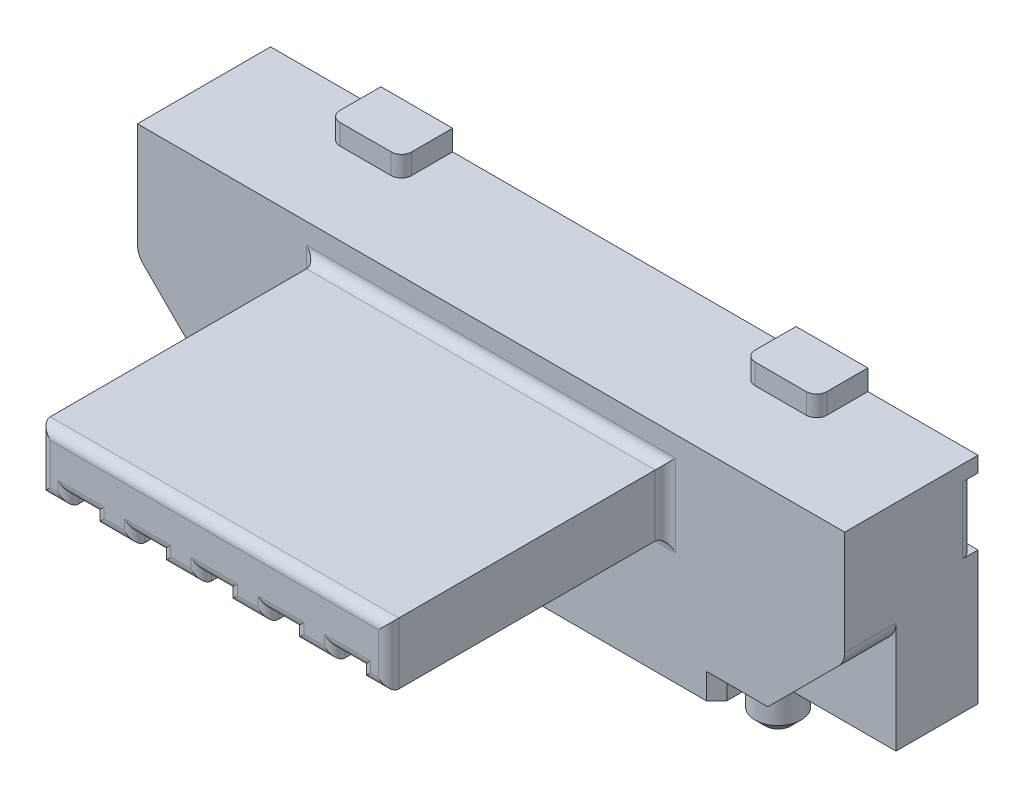
from build123d import *

# Parameters (mm, degrees)
SKETCH1_W           = 6.9
SKETCH1_H           = 1.3
BOSS_EXTRUDE1_DEPTH = 2.1
SKETCH2_W           = 3.4
SKETCH2_H           = 0.6
BOSS_EXTRUDE2_DEPTH = 2.7
SKETCH3_W           = 0.25
SKETCH3_H           = 0.1
CUT_EXTRUDE1_DEPTH  = 3
FILLET1_R           = 0.1
CUT_EXTRUDE2_DEPTH  = 0.5
FILLET3_R           = 0.2
CHAMFER1_SIZE       = 0.1
CUT_EXTRUDE3_DEPTH  = 0.05
FILLET4_R           = 0.1
SKETCH6_R           = 0.225
BOSS_EXTRUDE3_DEPTH = 0.6
CHAMFER2_SIZE       = 0.1
SKETCH7_W           = 3.4
SKETCH7_H           = 0.7
CUT_EXTRUDE4_DEPTH  = 0.3
BOSS_EXTRUDE4_DEPTH = 0.2


with BuildPart() as part:
    # Sketch1 → Boss-Extrude1 (new body)
    with BuildSketch(Plane(origin=(0, 0, 0), x_dir=(1, 0, 0), z_dir=(0, 1, 0))):
        with Locations((0, 4.15)):
            Rectangle(SKETCH1_W, SKETCH1_H)
    extrude(amount=BOSS_EXTRUDE1_DEPTH)

    # Sketch2 → Boss-Extrude2 (add)
    with BuildSketch(Plane.XY.offset(-3.5)):
        with Locations((0, 1.5)):
            Rectangle(SKETCH2_W, SKETCH2_H)
    extrude(amount=BOSS_EXTRUDE2_DEPTH)

    # Sketch3 → Cut-Extrude1 (cut)
    with BuildSketch(Plane.XY.offset(-0.8)):
        with Locations((-1.3, 1.25)):
            Rectangle(SKETCH3_W, SKETCH3_H)
        with Locations((-0.65, 1.25)):
            Rectangle(SKETCH3_W, SKETCH3_H)
        with Locations((0, 1.25)):
            Rectangle(SKETCH3_W, SKETCH3_H)
        with Locations((0.65, 1.25)):
            Rectangle(SKETCH3_W, SKETCH3_H)
        with Locations((1.3, 1.25)):
            Rectangle(SKETCH3_W, SKETCH3_H)
    extrude(amount=-CUT_EXTRUDE1_DEPTH, mode=Mode.SUBTRACT)

    # Fillet1
    fillet1_edges = [part.edges().sort_by_distance(p)[0] for p in [
        (0, 1.8, -0.8),
        (1.7, 1.5, -0.8),
        (1.5625, 1.2, -0.8),
        (-1.5625, 1.2, -0.8),
        (-1.7, 1.5, -0.8),
        (-1.7, 1.5, -3.5),
        (0, 1.8, -3.5),
        (1.7, 1.5, -3.5),
        (1.5625, 1.2, -3.5),
        (-1.5625, 1.2, -3.5),
        (0.975, 1.2, -0.8),
        (0.775, 1.25, -0.8),
        (0.65, 1.3, -0.8),
        (0.525, 1.25, -0.8),
        (0.325, 1.2, -0.8),
        (0.125, 1.25, -0.8),
        (0, 1.3, -0.8),
        (-0.125, 1.25, -0.8),
        (-0.325, 1.2, -0.8),
        (-0.525, 1.25, -0.8),
        (-0.65, 1.3, -0.8),
        (-0.775, 1.25, -0.8),
        (-0.975, 1.2, -0.8),
        (-1.175, 1.25, -0.8),
        (-1.3, 1.3, -0.8),
        (-1.425, 1.25, -0.8),
        (1.425, 1.25, -0.8),
        (1.3, 1.3, -0.8),
        (1.175, 1.25, -0.8),
        (0.975, 1.2, -3.5),
        (0.325, 1.2, -3.5),
        (-0.325, 1.2, -3.5),
        (-0.975, 1.2, -3.5),
    ]]
    fillet(fillet1_edges, radius=FILLET1_R)

    # Sketch4 → Cut-Extrude2 (cut)
    with BuildSketch(Plane.XY.offset(-3.5)):
        Polygon((-2.7, 0.25), (-3.45, 1), (-3.45, 0), (-2.2, 0), (-2.2, 0.25), align=None)
        Polygon((3.45, 1), (2.7, 0.25), (2.2, 0.25), (2.2, 0), (3.45, 0), align=None)
    extrude(amount=-CUT_EXTRUDE2_DEPTH, mode=Mode.SUBTRACT)

    # Fillet3
    fillet3_edges = [part.edges().sort_by_distance(p)[0] for p in [
        (-3.45, 1, -3.75),
        (3.45, 1, -3.75),
    ]]
    fillet(fillet3_edges, radius=FILLET3_R)

    # Chamfer1
    chamfer1_edges = [part.edges().sort_by_distance(p)[0] for p in [
        (-2.2, 0.125, -3.5),
        (2.2, 0.125, -3.5),
    ]]
    chamfer(chamfer1_edges, length=CHAMFER1_SIZE)

    # Sketch5 → Cut-Extrude3 (cut)
    with BuildSketch(Plane(origin=(0, 0, -4.8), x_dir=(-1, 0, 0), z_dir=(0, 0, -1))):
        with BuildLine():
            Line((-3.45, 1.95), (-2.25, 1.95))
            ThreePointArc((-2.25, 1.95), (-2.073223305, 1.876776695), (-2, 1.7))
            Line((-2, 1.7), (-2, 1.55))
            ThreePointArc((-2, 1.55), (-2.073223305, 1.373223305), (-2.25, 1.3))
            Line((-2.25, 1.3), (-3.45, 1.3))
            Line((-3.45, 1.3), (-3.45, 1.95))
        make_face()
        with BuildLine():
            Line((3.45, 1.95), (2.25, 1.95))
            ThreePointArc((2.25, 1.95), (2.073223305, 1.876776695), (2, 1.7))
            Line((2, 1.7), (2, 1.55))
            ThreePointArc((2, 1.55), (2.073223305, 1.373223305), (2.25, 1.3))
            Line((2.25, 1.3), (3.45, 1.3))
            Line((3.45, 1.3), (3.45, 1.95))
        make_face()
    extrude(amount=-CUT_EXTRUDE3_DEPTH, mode=Mode.SUBTRACT)

    # Fillet4
    fillet4_edges = [part.edges().sort_by_distance(p)[0] for p in [
        (3.45, 1.625, -4.75),
        (-3.45, 1.625, -4.75),
    ]]
    fillet(fillet4_edges, radius=FILLET4_R)

    # Sketch6 → Boss-Extrude3 (add)
    with BuildSketch(Plane.XZ):
        with Locations((2, -4.3)):
            Circle(SKETCH6_R)
        with Locations((-2, -4.3)):
            Circle(SKETCH6_R)
    extrude(amount=BOSS_EXTRUDE3_DEPTH)

    # Chamfer2
    chamfer2_edges = [part.edges().sort_by_distance(p)[0] for p in [
        (1.775, -0.6, -4.3),
        (-2.225, -0.6, -4.3),
    ]]
    chamfer(chamfer2_edges, length=CHAMFER2_SIZE)

    # Sketch7 → Cut-Extrude4 (cut)
    with BuildSketch(Plane.XZ):
        with Locations((0, -4.45)):
            Rectangle(SKETCH7_W, SKETCH7_H)
    extrude(amount=-CUT_EXTRUDE4_DEPTH, mode=Mode.SUBTRACT)

    # Sketch8 → Boss-Extrude4 (add)
    with BuildSketch(Plane(origin=(0, 2.1, 0), x_dir=(1, 0, 0), z_dir=(0, 1, 0))):
        with BuildLine():
            Line((-2.375, 4.8), (-1.675, 4.8))
            Line((-1.675, 4.8), (-1.675, 4.4))
            ThreePointArc((-1.675, 4.4), (-1.704289322, 4.329289322), (-1.775, 4.3))
            Line((-1.775, 4.3), (-2.275, 4.3))
            ThreePointArc((-2.275, 4.3), (-2.345710678, 4.329289322), (-2.375, 4.4))
            Line((-2.375, 4.4), (-2.375, 4.8))
        make_face()
        with BuildLine():
            Line((1.675, 4.8), (2.375, 4.8))
            Line((2.375, 4.8), (2.375, 4.4))
            ThreePointArc((2.375, 4.4), (2.345710678, 4.329289322), (2.275, 4.3))
            Line((2.275, 4.3), (1.775, 4.3))
            ThreePointArc((1.775, 4.3), (1.704289322, 4.329289322), (1.675, 4.4))
            Line((1.675, 4.4), (1.675, 4.8))
        make_face()
    extrude(amount=BOSS_EXTRUDE4_DEPTH)


solid = part.part
